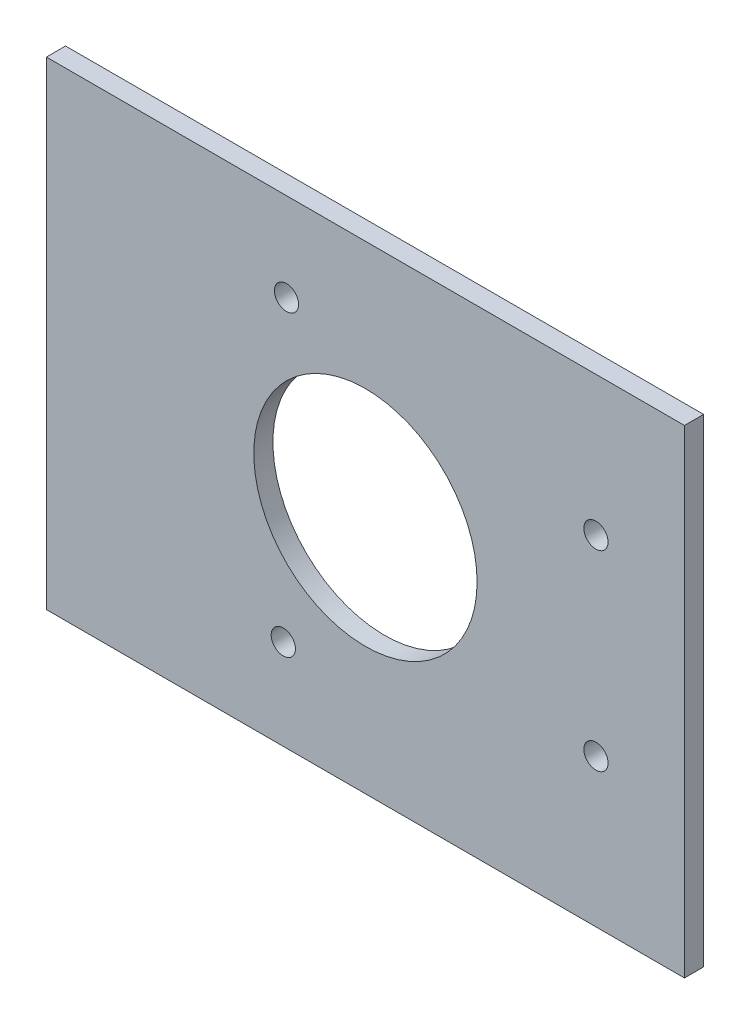
from build123d import *

# Parameters (mm, degrees)
CROQUIS1_W              = 100
CROQUIS1_H              = 75
CROQUIS1_R              = 17.5
CROQUIS1_R_2            = 1.9
SALIENTE_EXTRUIR1_DEPTH = 3


with BuildPart() as part:
    # Croquis1 → Saliente-Extruir1 (new body)
    with BuildSketch(Plane.XY):
        Rectangle(CROQUIS1_W, CROQUIS1_H)
        Circle(CROQUIS1_R, mode=Mode.SUBTRACT)
        with Locations((-12.871280309, -23.326223098)):
            Circle(CROQUIS1_R_2, mode=Mode.SUBTRACT)
        with Locations((36.128719631, -14.326222516)):
            Circle(CROQUIS1_R_2, mode=Mode.SUBTRACT)
        with Locations((36.128719631, 15.673777484)):
            Circle(CROQUIS1_R_2, mode=Mode.SUBTRACT)
        with Locations((-12.37128089, 23.673777603)):
            Circle(CROQUIS1_R_2, mode=Mode.SUBTRACT)
    extrude(amount=SALIENTE_EXTRUIR1_DEPTH)


solid = part.part
